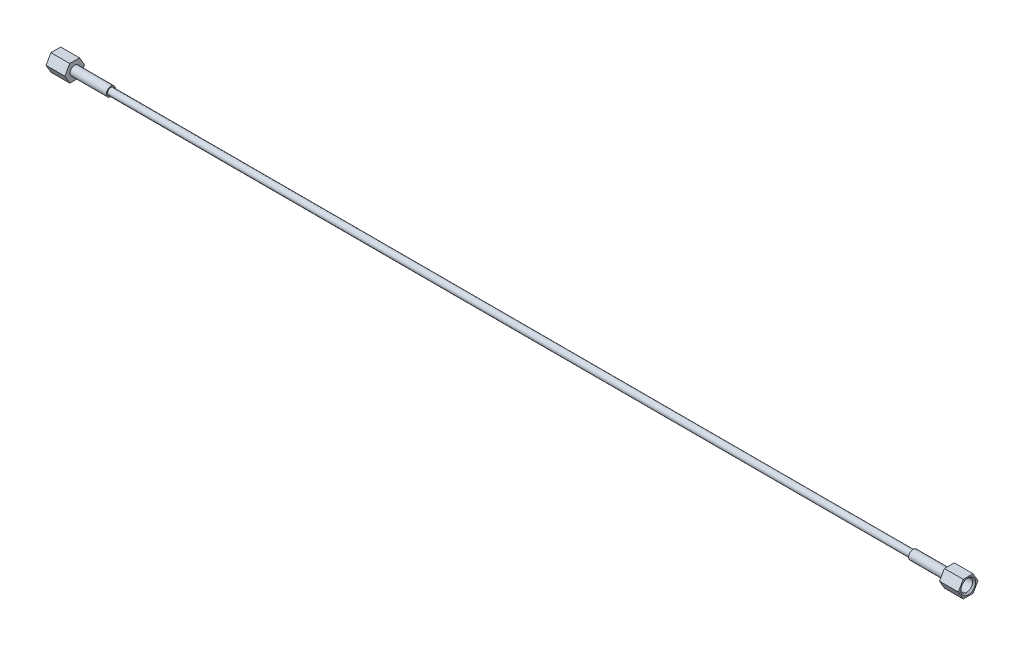
from build123d import *

# Parameters (mm, degrees)
EXTRUDE2_DEPTH = 15.748
CHAMFER2_SIZE  = 1.240155


with BuildPart() as part:
    # Sketch5 → Extrude2 (new body)
    with BuildSketch(Plane(origin=(-6.858, 0, 0), x_dir=(0, 0, -1), z_dir=(1, 0, 0))):
        Polygon((4.106115114, 7.112), (-4.106115114, 7.112), (-8.212230229, 0), (-4.106115114, -7.112), (4.106115114, -7.112), (8.212230229, 0), align=None)
    extrude(amount=EXTRUDE2_DEPTH)

    # Sketch6 → Hole2 (revolve, cut)
    with BuildSketch(Plane(origin=(8.89, 0, 0), x_dir=(0, 0, -1), z_dir=(0, 1, 0))):
        Polygon((0, 0), (0, 15.748), (3.8354, 15.748), (3.8354, 9.566100386), (4.96062, 8.89), (4.96062, 0), align=None)
    revolve(axis=Axis((15.020023899, 0, 0), (-1, 0, 0)), mode=Mode.SUBTRACT)

    # Chamfer2
    chamfer2_edges = [part.edges().sort_by_distance(p)[0] for p in [
        (8.89, 0, 4.96062),
    ]]
    chamfer(chamfer2_edges, length=CHAMFER2_SIZE)


with BuildPart() as body_2:
    # Sketch8 → Revolve2 (revolve)
    with BuildSketch(Plane(origin=(0, 0, 0), x_dir=(-1, 0, 0), z_dir=(0, 0, -1)), mode=Mode.PRIVATE) as revolve2_sk:
        Polygon((0.691362245, 3.81), (2.385428675, 0.9906), (741.834571325, 0.9906), (743.528637755, 3.81), (707.136, 3.81), (707.136, 2.7686), (37.084, 2.7686), (37.084, 3.81), align=None)
    revolve(revolve2_sk.sketch.rotate(Axis((-0.691362245, 0, 0), (-1, 0, 0)), 270), axis=Axis((-0.691362245, 0, 0), (-1, 0, 0)))  # turned: the seam where the file's is


with BuildPart() as body_3:
    # Mirror2: mirrored copy
    add(part.part.mirror(Plane(origin=(-372.11, 0, 0), x_dir=(0, 0, 1), z_dir=(1, 0, 0))))


solid = Compound([part.part, body_2.part, body_3.part])
